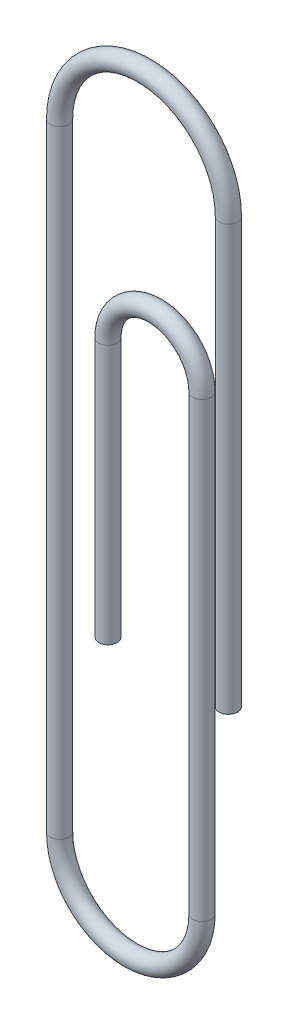
from build123d import *

# Parameters (mm, degrees)
SWEEP1_PROFILE_R = 0.38


with BuildPart() as part:
    # Sweep1: sweep along a path in Sketch1
    with BuildLine(Plane.XY) as sweep1_path:
        Line((0, 0), (0, 17.38))
        ThreePointArc((0, 17.38), (-3.455, 20.835), (-6.91, 17.38))
        Line((-6.91, 17.38), (-6.91, -7.89))
        ThreePointArc((-6.91, -7.89), (-3.995, -10.805), (-1.08, -7.89))
        Line((-1.08, -7.89), (-1.08, 10.62))
        ThreePointArc((-1.08, 10.62), (-3.005, 12.545), (-4.93, 10.62))
        Line((-4.93, 10.62), (-4.93, 0))
    # Sweep1 profile (on start of the path) → Sweep1 (sweep)
    with BuildSketch(Plane.ZX):
        Circle(SWEEP1_PROFILE_R)
    sweep(path=sweep1_path.line)


solid = part.part
